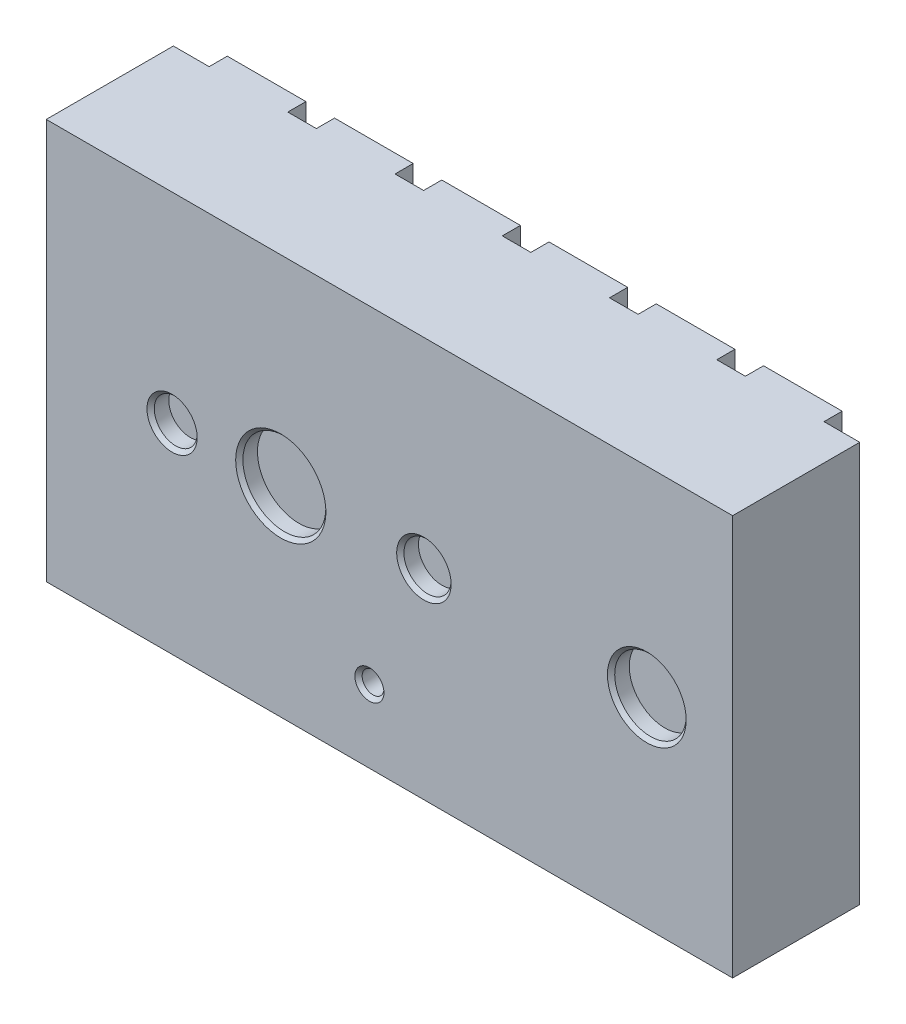
from build123d import *

# Parameters (mm, degrees)
SKETCH1_W            = 4.8
SKETCH1_H            = 2.7999944
BOSS_EXTRUDE3_DEPTH  = 0.889
SKETCH5_R            = 0.15
SKETCH5_R_2          = 0.29
SKETCH5_R_3          = 0.1651
SKETCH5_R_4          = 0.0762
SKETCH5_R_5          = 0.25
CUT_EXTRUDE2_DEPTH   = 0.127
CHAMFER2_SIZE        = 0.0254
SKETCH6_W            = 0.55
SKETCH6_H            = 0.7
BOSS_EXTRUDE4_DEPTH  = 0.127
LPATTERN1_COUNT      = 6
LPATTERN1_PITCH      = 0.75
LPATTERN1_COUNT_DIR2 = 2
LPATTERN1_PITCH_DIR2 = 2.1


with BuildPart() as part:
    # Sketch1 → Boss-Extrude3 (new body)
    with BuildSketch(Plane.XY):
        with Locations((2.4, 1.3999972)):
            Rectangle(SKETCH1_W, SKETCH1_H)
    extrude(amount=BOSS_EXTRUDE3_DEPTH)

    # Sketch5 → Cut-Extrude2 (cut)
    with BuildSketch(Plane.XY.offset(0.889)):
        with Locations((0.88, 1.3999972)):
            Circle(SKETCH5_R)
        with Locations((1.64, 1.3999972)):
            Circle(SKETCH5_R_2)
        with Locations((2.641, 1.3999972)):
            Circle(SKETCH5_R_3)
        with Locations((2.26, 0.508)):
            Circle(SKETCH5_R_4)
        with Locations((4.2, 1.3999972)):
            Circle(SKETCH5_R_5)
    extrude(amount=-CUT_EXTRUDE2_DEPTH, mode=Mode.SUBTRACT)

    # Chamfer2
    chamfer2_edges = [part.edges().sort_by_distance(p)[0] for p in [
        (0.73, 1.3999972, 0.889),
        (1.35, 1.3999972, 0.889),
        (2.4759, 1.3999972, 0.889),
        (2.1838, 0.508, 0.889),
        (3.95, 1.3999972, 0.889),
    ]]
    chamfer(chamfer2_edges, length=CHAMFER2_SIZE)


with BuildPart() as body_2:
    # Sketch6 → Boss-Extrude4 (new body)
    with BuildSketch(Plane(origin=(0, 0, 0), x_dir=(-1, 0, 0), z_dir=(0, 0, -1))):
        with Locations((-0.525, 0.35)):
            Rectangle(SKETCH6_W, SKETCH6_H)
    boss_extrude4 = extrude(amount=BOSS_EXTRUDE4_DEPTH)


with BuildPart() as part_1:
    add(part.part)

    # LPattern1: Boss-Extrude4 6 × 2
    with Locations(*[(i * LPATTERN1_PITCH, j * LPATTERN1_PITCH_DIR2, 0) for i in range(LPATTERN1_COUNT) for j in range(LPATTERN1_COUNT_DIR2) if (i, j) != (0, 0)]):
        add(boss_extrude4)


solid = Compound([body_2.part, part_1.part])
